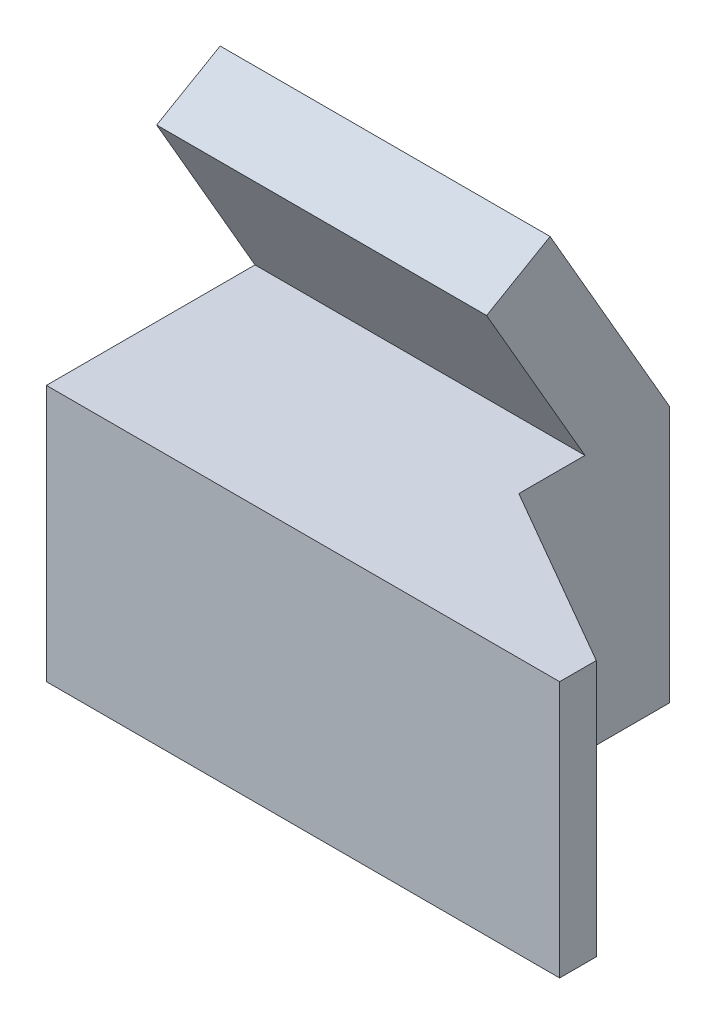
from build123d import *

# Parameters (mm, degrees)
BOSS_EXTRUDE1_DEPTH = 44.45
SKETCH3_R           = 9.525
CUT_EXTRUDE1_DEPTH  = 6.35
BOSS_EXTRUDE2_DEPTH = 57.15
SKETCH5_R           = 9.525
CUT_EXTRUDE2_DEPTH  = 6.35
SKETCH6_R           = 4.7625
CUT_EXTRUDE3_DEPTH  = 12.7


with BuildPart() as part:
    # Sketch1 → Boss-Extrude1 (new body)
    with BuildSketch(Plane(origin=(0, 0, 0), x_dir=(1, 0, 0), z_dir=(0, 1, 0))):
        Polygon((57.15, 0), (88.9, 0), (88.9, 6.35), (57.15, 24.680871047), (57.15, 50.8), (0, 50.8), (0, 0), align=None)
    extrude(amount=BOSS_EXTRUDE1_DEPTH)

    # Sketch3 → Cut-Extrude1 (cut)
    with BuildSketch(Plane(origin=(24.974630657, 0, -43.257329198), x_dir=(-0.866025404, 0, -0.5), z_dir=(0.5, 0, -0.866025404))):
        with Locations((-54.764658396, 22.352)):
            Circle(SKETCH3_R)
    extrude(amount=-CUT_EXTRUDE1_DEPTH, mode=Mode.SUBTRACT)

    # Sketch4 → Boss-Extrude2 (add)
    with BuildSketch(Plane.ZY):
        Polygon((-50.8, 44.45), (-30.099, 80.305183767), (-19.100477372, 73.955183767), (-36.135303163, 44.45), (0, 44.45), (0, 0), (-50.8, 0), align=None)
    extrude(amount=-BOSS_EXTRUDE2_DEPTH)

    # Sketch5 → Cut-Extrude2 (cut)
    with BuildSketch(Plane(origin=(0, 33.109545256, -57.347414599), x_dir=(-1, 0, 0), z_dir=(0, 0.5, -0.866025404))):
        with Locations((-28.702, 35.446829198)):
            Circle(SKETCH5_R)
    extrude(amount=-CUT_EXTRUDE2_DEPTH, mode=Mode.SUBTRACT)

    # Sketch6 → Cut-Extrude3 (cut)
    with BuildSketch(Plane(origin=(0, 0, -50.8), x_dir=(-1, 0, 0), z_dir=(0, 0, -1))):
        with Locations((-41.148, 31.75)):
            Circle(SKETCH6_R)
        with Locations((-16.002, 31.75)):
            Circle(SKETCH6_R)
        with Locations((-16.002, 12.7)):
            Circle(SKETCH6_R)
        with Locations((-41.148, 12.7)):
            Circle(SKETCH6_R)
    extrude(amount=-CUT_EXTRUDE3_DEPTH, mode=Mode.SUBTRACT)


solid = part.part
